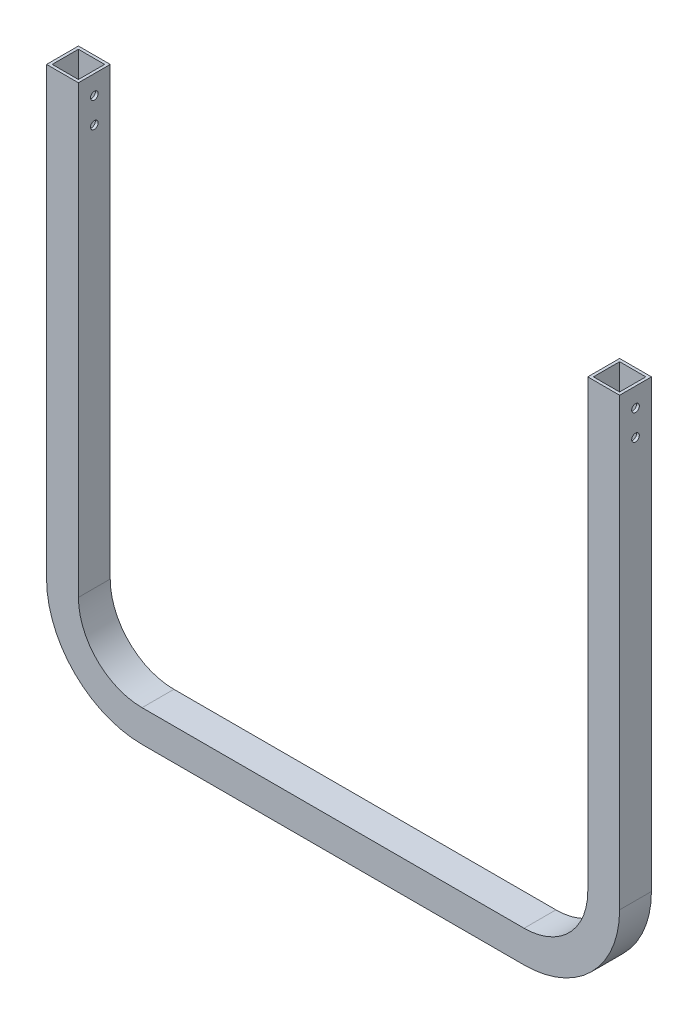
from build123d import *

# Parameters (mm, degrees)
EXTRUDE_1_DEPTH     = 25
SHELL_1_T           = -2.2
SKETCH_2_W          = 20.6
SKETCH_2_H          = 20.6
CUT_EXTRUDE_1_DEPTH = 5
SKETCH_3_R          = 3
CUT_EXTRUDE_2_DEPTH = 451


with BuildPart() as part:
    # Эскиз1 → Бобышка-Вытянуть1 (new body)
    with BuildSketch(Plane.XY):
        with BuildLine():
            Line((-260.93597277, 123.115577889), (-260.93597277, -226.884422111))
            ThreePointArc((-260.93597277, -226.884422111), (-238.968981359, -279.9174307), (-185.93597277, -301.884422111))
            Line((-185.93597277, -301.884422111), (114.06402723, -301.884422111))
            ThreePointArc((114.06402723, -301.884422111), (167.097035819, -279.9174307), (189.06402723, -226.884422111))
            Line((189.06402723, -226.884422111), (189.06402723, 123.115577889))
            Line((189.06402723, 123.115577889), (164.06402723, 123.115577889))
            Line((164.06402723, 123.115577889), (164.06402723, -226.884422111))
            ThreePointArc((164.06402723, -226.884422111), (149.419366289, -262.23976117), (114.06402723, -276.884422111))
            Line((114.06402723, -276.884422111), (-185.93597277, -276.884422111))
            ThreePointArc((-185.93597277, -276.884422111), (-221.291311829, -262.23976117), (-235.93597277, -226.884422111))
            Line((-235.93597277, -226.884422111), (-235.93597277, 123.115577889))
            Line((-235.93597277, 123.115577889), (-260.93597277, 123.115577889))
        make_face()
    extrude(amount=EXTRUDE_1_DEPTH)

    # Оболочка1
    shell_1_openings = [part.faces().sort_by_distance(p)[0] for p in [
        (-248.43597277, 123.115577889, 12.5),
    ]]
    offset(amount=SHELL_1_T, openings=shell_1_openings, kind=Kind.INTERSECTION)

    # Эскиз2 → Вырез-Вытянуть1 (cut)
    with BuildSketch(Plane(origin=(0, 123.115577889, 0), x_dir=(1, 0, 0), z_dir=(0, 1, 0))):
        with Locations((176.56402723, -12.5)):
            Rectangle(SKETCH_2_W, SKETCH_2_H)
    extrude(amount=-CUT_EXTRUDE_1_DEPTH, mode=Mode.SUBTRACT)

    # Эскиз3 → Вырез-Вытянуть2 (cut, through all)
    with BuildSketch(Plane.ZY.offset(260.93597277)):
        with Locations(Location((12.5, 108.115577889, 0), (0, 0, 270))):  # turned: the seam where the file's is
            Circle(SKETCH_3_R)
        with Locations(Location((12.5, 88.115577889, 0), (0, 0, 270))):  # turned: the seam where the file's is
            Circle(SKETCH_3_R)
    extrude(amount=-CUT_EXTRUDE_2_DEPTH, mode=Mode.SUBTRACT)


solid = part.part
